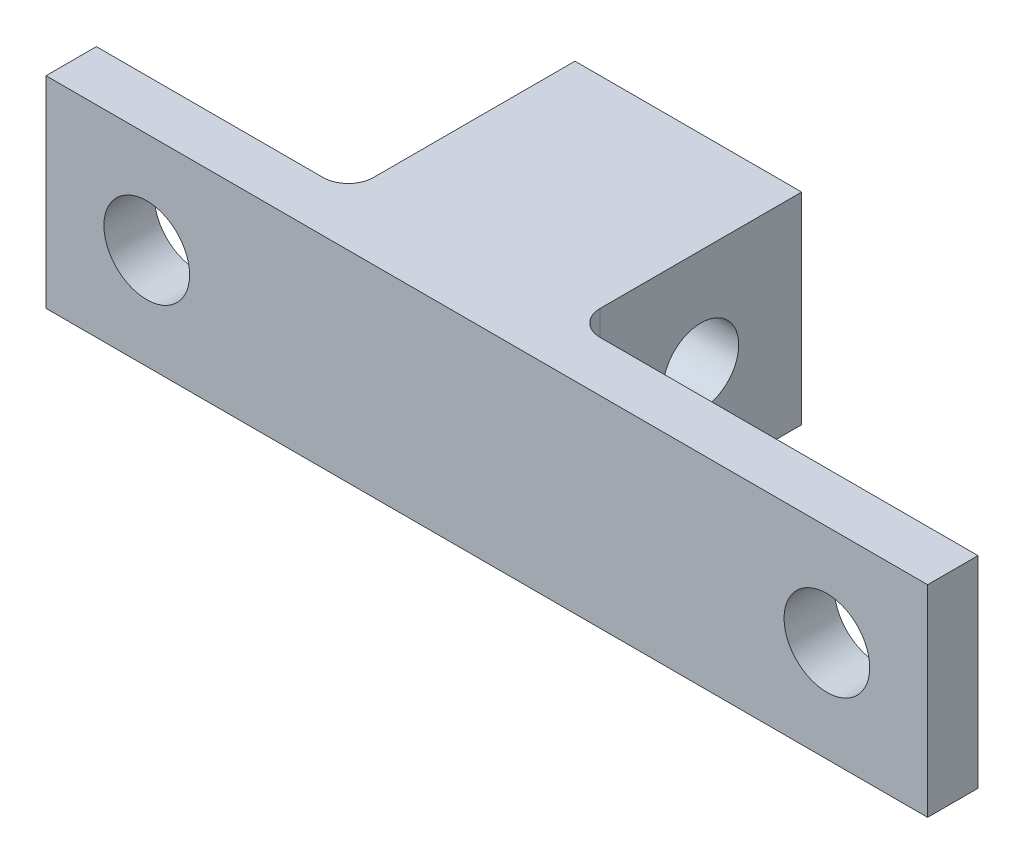
from build123d import *

# Parameters (mm, degrees)
BOSS_EXTRUDE1_DEPTH      = 8
M3_CLEARANCE_HOLE1_D     = 3.4
M3_CLEARANCE_HOLE1_DEPTH = 3.9
M3_CLEARANCE_HOLE1_TIP   = 1.021463052
SKETCH4_R                = 1.5
CUT_EXTRUDE1_DEPTH       = 26
FILLET1_R                = 1


with BuildPart() as part:
    # Sketch1 → Boss-Extrude1 (new body)
    with BuildSketch(Plane(origin=(0, 0, 0), x_dir=(1, 0, 0), z_dir=(0, 1, 0))):
        Polygon((0, 0), (10, 0), (10, 9), (19, 9), (19, 0), (35, 0), (35, -2), (0, -2), align=None)
    extrude(amount=BOSS_EXTRUDE1_DEPTH)

    # M3 Clearance Hole1
    with Locations(Plane(origin=(0, 0, 0), x_dir=(-1, 0, 0), z_dir=(0, 0, -1))):
        with Locations((-4, 4), (-31, 4)):
            Hole(M3_CLEARANCE_HOLE1_D / 2, depth=M3_CLEARANCE_HOLE1_DEPTH)
            with Locations((0, 0, -(M3_CLEARANCE_HOLE1_DEPTH + M3_CLEARANCE_HOLE1_TIP / 2))):  # 118° drill point
                Cone(0, M3_CLEARANCE_HOLE1_D / 2, M3_CLEARANCE_HOLE1_TIP, mode=Mode.SUBTRACT)

    # Sketch4 → Cut-Extrude1 (cut, through all)
    with BuildSketch(Plane.ZY.offset(-10)):
        with Locations((-5, 4)):
            Circle(SKETCH4_R)
    extrude(amount=-CUT_EXTRUDE1_DEPTH, mode=Mode.SUBTRACT)

    # Fillet1
    fillet1_edges = [part.edges().sort_by_distance(p)[0] for p in [
        (19, 4, 0),
        (10, 4, 0),
    ]]
    fillet(fillet1_edges, radius=FILLET1_R)


solid = part.part
